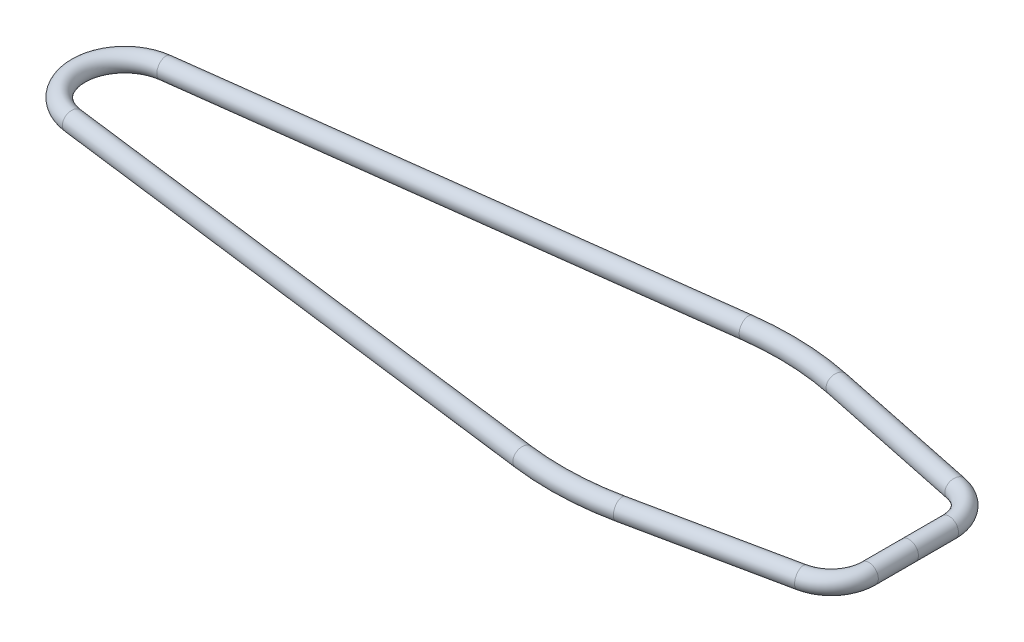
from build123d import *

# Parameters (mm, degrees)
SKETCH2_R   = 12.7
SKETCH2_R_2 = 11.1125


with BuildPart() as part:
    # Sweep1: sweep along a path in Sketch1
    with BuildLine(Plane(origin=(0, 0, 0), x_dir=(1, 0, 0), z_dir=(0, 1, 0))) as sweep1_path:
        Line((-7.906529263, 61.9125), (686.985321151, 150.653590246))
        ThreePointArc((686.985321151, 150.653590246), (750.176111833, 153.430347782), (812.955493844, 145.714415968))
        Line((812.955493844, 145.714415968), (1014.745566599, 103.674817477))
        ThreePointArc((1014.745566599, 103.674817477), (1043.798980451, 85.991851566), (1055.18469049, 53.942612155))
        Line((1055.18469049, 53.942612155), (1055.18469049, -53.942612155))
        ThreePointArc((1055.18469049, -53.942612155), (1043.798980451, -85.991851566), (1014.745566599, -103.674817477))
        Line((1014.745566599, -103.674817477), (812.955493844, -145.714415968))
        ThreePointArc((812.955493844, -145.714415968), (750.176111833, -153.430347782), (686.985321151, -150.653590246))
        Line((686.985321151, -150.653590246), (-7.906529263, -61.9125))
        ThreePointArc((-7.906529263, -61.9125), (-62.41530951, 0), (-7.906529263, 61.9125))
    # Sketch2 → Sweep1 (sweep)
    with BuildSketch(Plane.XY):
        with Locations((1055.18469049, 0)):
            Circle(SKETCH2_R)
        with Locations((1055.18469049, 0)):
            Circle(SKETCH2_R_2, mode=Mode.SUBTRACT)
    sweep(path=sweep1_path.line)


solid = part.part
